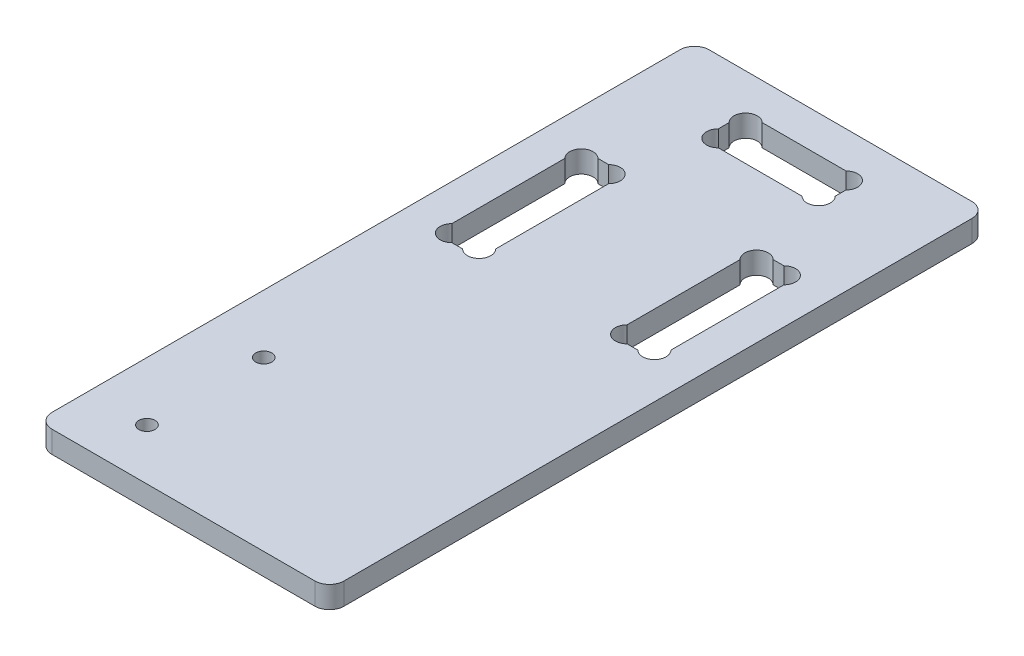
from build123d import *

# Parameters (mm, degrees)
EXTRUSION1_DEPTH        = 3
ESQUISSE2_R             = 1.1
ENL_V_MAT_EXTRU_1_DEPTH = 4


with BuildPart() as part:
    # Esquisse1 → Extrusion1 (new body)
    with BuildSketch(Plane(origin=(0, 0, 0), x_dir=(1, 0, 0), z_dir=(0, 1, 0))):
        with BuildLine():
            Line((13, 2), (13, 88))
            ThreePointArc((13, 88), (13.585786438, 89.414213562), (15, 90))
            Line((15, 90), (51, 90))
            ThreePointArc((51, 90), (52.414213562, 89.414213562), (53, 88))
            Line((53, 88), (53, 2))
            ThreePointArc((53, 2), (52.414213562, 0.585786438), (51, 0))
            Line((51, 0), (15, 0))
            ThreePointArc((15, 0), (13.585786438, 0.585786438), (13, 2))
        make_face()
    extrude(amount=EXTRUSION1_DEPTH)

    # Esquisse2 → Enlèv. mat.-Extru.1 (cut, through all)
    with BuildSketch(Plane.XZ):
        with Locations(Location((21, -7, 0), (0, 0, 90))):  # turned: the seam where the file's is
            Circle(ESQUISSE2_R)
        with Locations(Location((21, -23, 0), (0, 0, 90))):  # turned: the seam where the file's is
            Circle(ESQUISSE2_R)
        with BuildLine():
            Line((41, -82.7372583), (41, -81.2627417))
            ThreePointArc((41, -81.2627417), (41, -79), (38.7372583, -79))
            Line((38.7372583, -79), (27.2627417, -79))
            ThreePointArc((27.2627417, -79), (25, -79), (25, -81.2627417))
            Line((25, -81.2627417), (25, -82.7372583))
            ThreePointArc((25, -82.7372583), (25, -85), (27.2627417, -85))
            Line((27.2627417, -85), (38.7372583, -85))
            ThreePointArc((38.7372583, -85), (41, -85), (41, -82.7372583))
        make_face()
        with BuildLine():
            Line((45.7372583, -49.5), (44.2627417, -49.5))
            ThreePointArc((44.2627417, -49.5), (42, -49.5), (42, -51.7627417))
            Line((42, -51.7627417), (42, -67.2372583))
            ThreePointArc((42, -67.2372583), (42, -69.5), (44.2627417, -69.5))
            Line((44.2627417, -69.5), (45.7372583, -69.5))
            ThreePointArc((45.7372583, -69.5), (48, -69.5), (48, -67.2372583))
            Line((48, -67.2372583), (48, -51.7627417))
            ThreePointArc((48, -51.7627417), (48, -49.5), (45.7372583, -49.5))
        make_face()
        with BuildLine():
            Line((24, -67.2372583), (24, -51.7627417))
            ThreePointArc((24, -51.7627417), (24, -49.5), (21.7372583, -49.5))
            Line((21.7372583, -49.5), (20.2627417, -49.5))
            ThreePointArc((20.2627417, -49.5), (18, -49.5), (18, -51.7627417))
            Line((18, -51.7627417), (18, -67.2372583))
            ThreePointArc((18, -67.2372583), (18, -69.5), (20.2627417, -69.5))
            Line((20.2627417, -69.5), (21.7372583, -69.5))
            ThreePointArc((21.7372583, -69.5), (24, -69.5), (24, -67.2372583))
        make_face()
    extrude(amount=-ENL_V_MAT_EXTRU_1_DEPTH, mode=Mode.SUBTRACT)


solid = part.part
